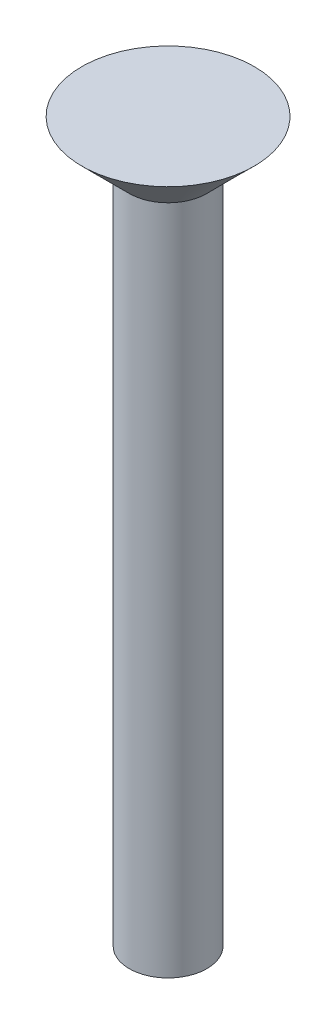
from build123d import *

# Parameters (mm, degrees)
THREADS_W = 1.35
THREADS_H = 23.35


with BuildPart() as part:
    # Threads → Revolve1 (revolve)
    with BuildSketch(Plane.XY):
        with Locations((0.675, 0)):
            Rectangle(THREADS_W, THREADS_H)
    revolve(axis=Axis((0, -5.706647399, 0), (0, 1, 0)))

    # Sketch5 → Flat (revolve)
    with BuildSketch(Plane.XY):
        Polygon((0, 13.325), (0, 11.675), (1.35, 11.675), (3, 13.325), align=None)
    revolve(axis=Axis((0, -1.12148781, 0), (0, 1, 0)))


solid = part.part
